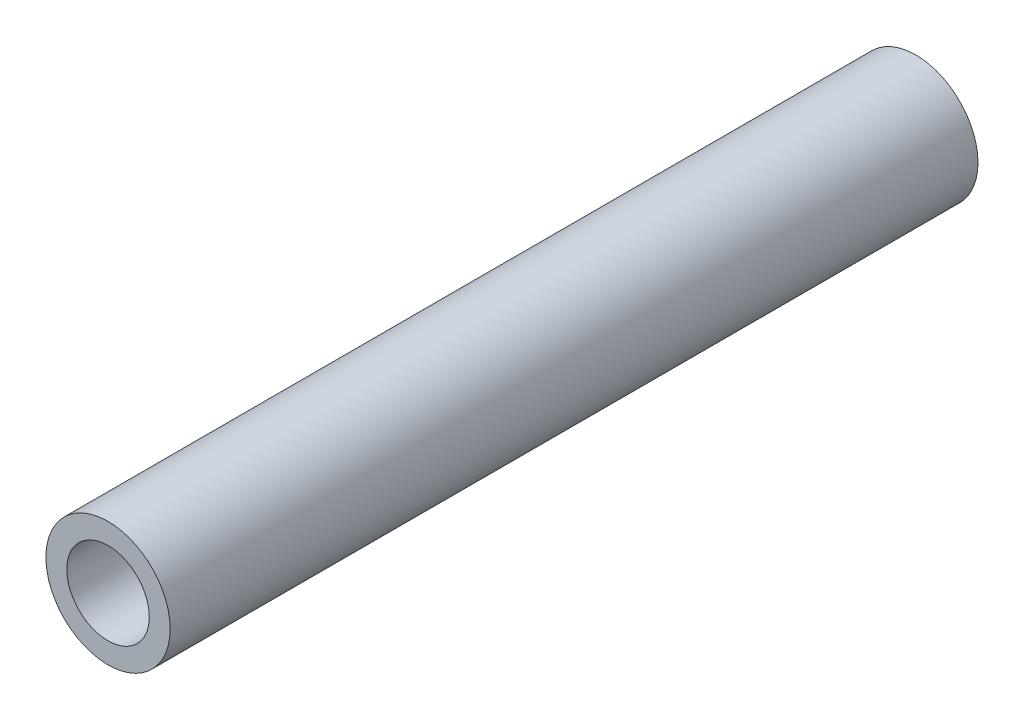
from build123d import *

# Parameters (mm, degrees)
SKETCH1_R           = 3.175
SKETCH1_R_2         = 2.1082
BOSS_EXTRUDE1_DEPTH = 41.275
CHAMFER1_SIZE       = 0.254


with BuildPart() as part:
    # Sketch1 → Boss-Extrude1 (new body)
    with BuildSketch(Plane.XY):
        Circle(SKETCH1_R)
        Circle(SKETCH1_R_2, mode=Mode.SUBTRACT)
    extrude(amount=-BOSS_EXTRUDE1_DEPTH)

    # Chamfer1
    chamfer1_edges = [part.edges().sort_by_distance(p)[0] for p in [
        (-2.1082, 0, -41.275),
    ]]
    chamfer(chamfer1_edges, length=CHAMFER1_SIZE)


solid = part.part
